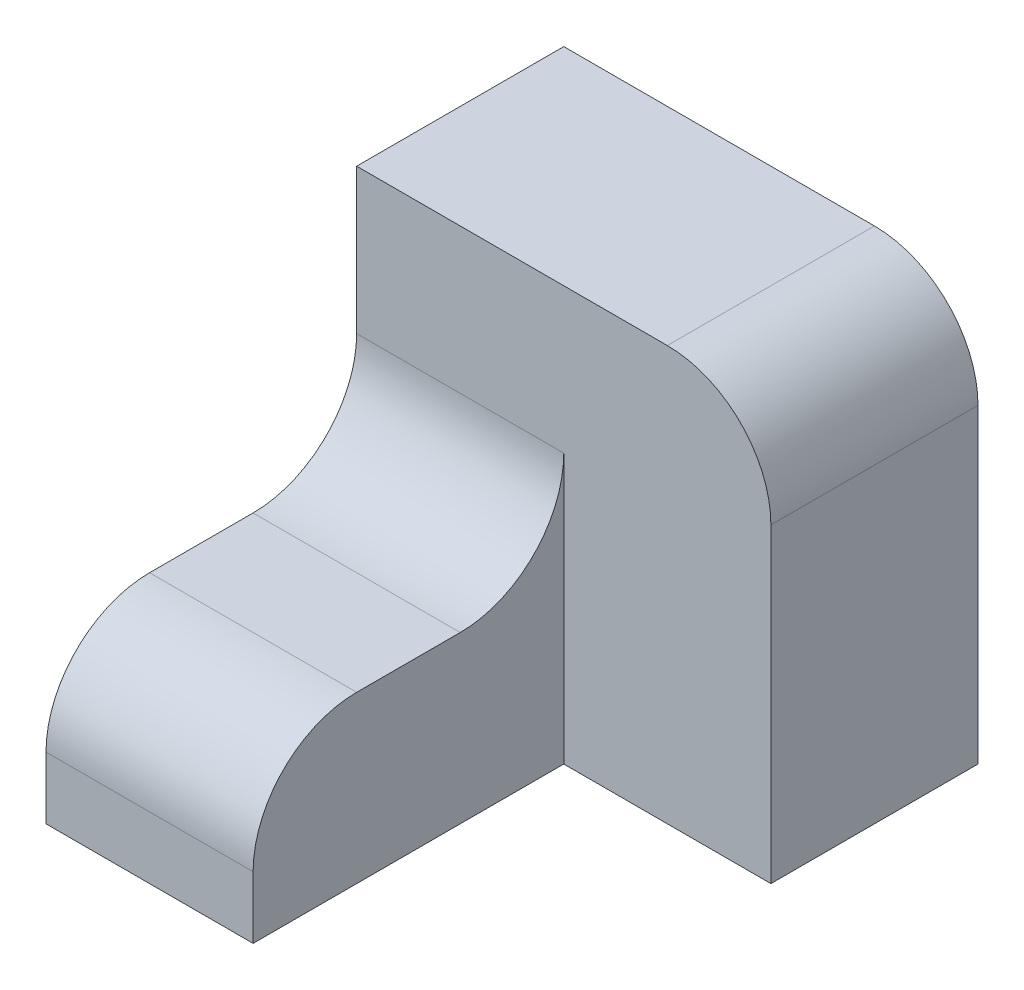
from build123d import *

# Parameters (mm, degrees)
SKETCH1_W           = 20
SKETCH1_H           = 16
BOSS_EXTRUDE1_DEPTH = 30
SKETCH2_W           = 40
SKETCH2_H           = 40
BOSS_EXTRUDE2_DEPTH = 20
FILLET1_R           = 10


with BuildPart() as part:
    # Sketch1 → Boss-Extrude1 (new body)
    with BuildSketch(Plane.XY):
        with Locations((-20, -8)):
            Rectangle(SKETCH1_W, SKETCH1_H)
    extrude(amount=BOSS_EXTRUDE1_DEPTH)

    # Sketch2 → Boss-Extrude2 (add)
    with BuildSketch(Plane.XY):
        with Locations((-10, 4)):
            Rectangle(SKETCH2_W, SKETCH2_H)
    extrude(amount=-BOSS_EXTRUDE2_DEPTH)

    # Fillet1
    fillet1_edges = [part.edges().sort_by_distance(p)[0] for p in [
        (10, 24, -10),
        (-20, 0, 30),
        (-20, 0, 0),
    ]]
    fillet(fillet1_edges, radius=FILLET1_R)


solid = part.part
